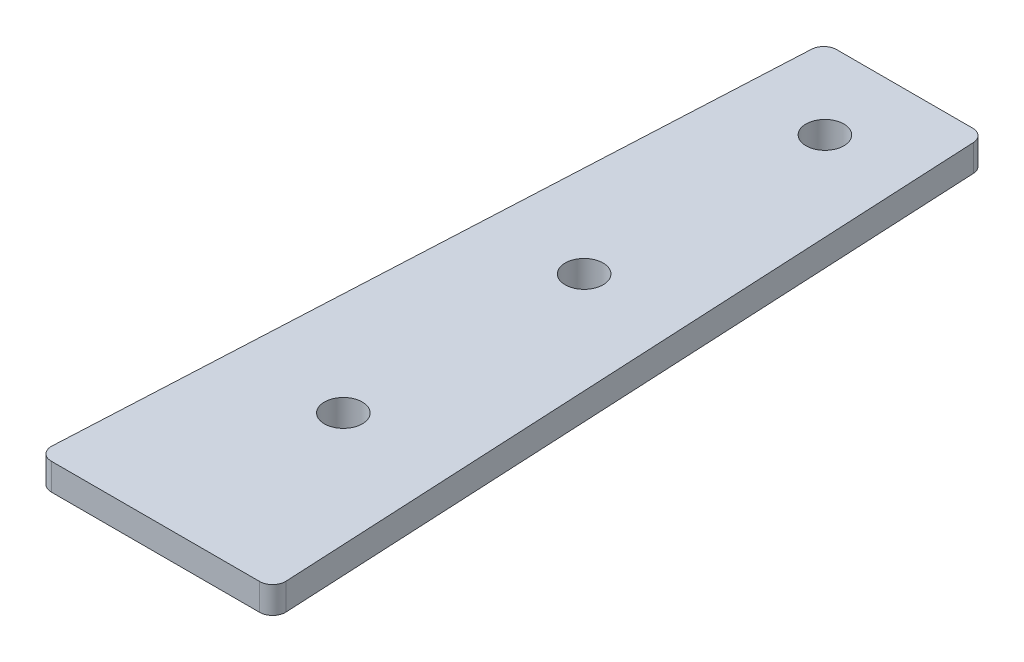
from build123d import *

# Parameters (mm, degrees)
BOSS_EXTRUDE1_DEPTH  = 3.175
M4_CLEARANCE_HOLE1_D = 4.5


with BuildPart() as part:
    # Sketch1 → Boss-Extrude1 (new body)
    with BuildSketch(Plane(origin=(0, 0, 0), x_dir=(1, 0, 0), z_dir=(0, 1, 0))):
        with BuildLine():
            Line((-75.32, 38.035000003), (-67.244703811, 38.035000003))
            ThreePointArc((-67.244703811, 38.035000003), (-66.19432481, 37.615210108), (-65.722605246, 36.587104931))
            Line((-65.722605246, 36.587104931), (-61.430005246, -49.264895069))
            ThreePointArc((-61.430005246, -49.264895069), (-61.847893706, -50.391378998), (-62.952103811, -50.864999997))
            Line((-62.952103811, -50.864999997), (-75.32, -50.864999997))
            Line((-75.32, -50.864999997), (-87.687896189, -50.864999997))
            ThreePointArc((-87.687896189, -50.864999997), (-88.792106294, -50.391378998), (-89.209994754, -49.264895069))
            Line((-89.209994754, -49.264895069), (-84.917394754, 36.587104931))
            ThreePointArc((-84.917394754, 36.587104931), (-84.44567519, 37.615210108), (-83.395296189, 38.035000003))
            Line((-83.395296189, 38.035000003), (-75.32, 38.035000003))
        make_face()
    extrude(amount=BOSS_EXTRUDE1_DEPTH)

    # M4 Clearance Hole1 (through all)
    with Locations(Plane(origin=(0, 3.175, 0), x_dir=(1, 0, 0), z_dir=(0, 1, 0))):
        with Locations((-75.32, 28.575), (-75.32, 0), (-75.32, -28.575)):
            Hole(M4_CLEARANCE_HOLE1_D / 2)


solid = part.part
